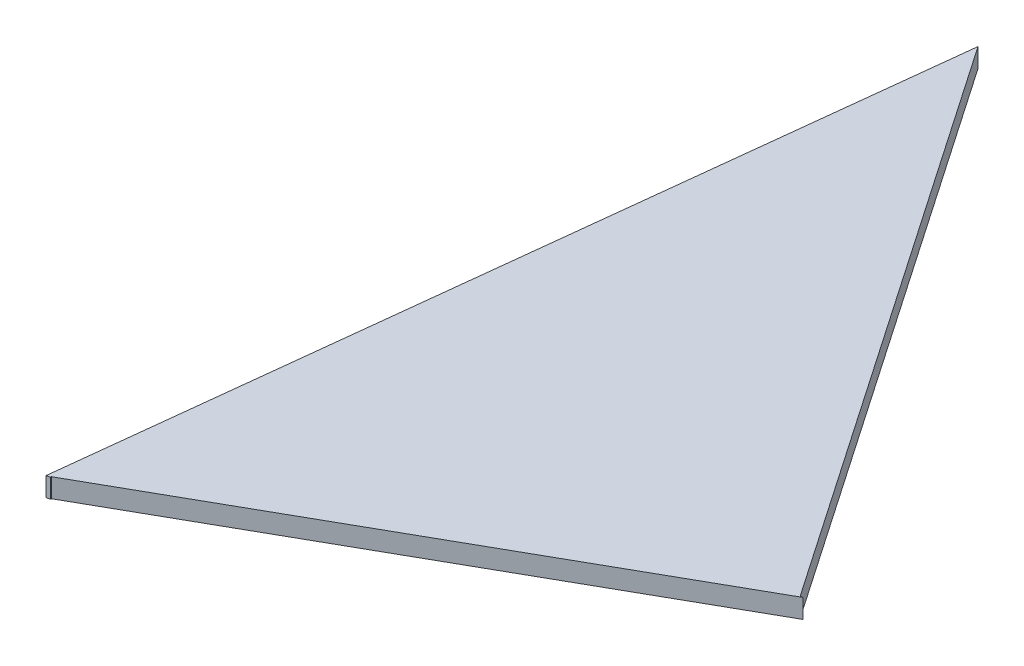
from build123d import *

# Parameters (mm, degrees)
BOSS_EXTRU_1_DEPTH = 2


with BuildPart() as part:
    # Esquisse1 → Boss.-Extru.1 (new body)
    with BuildSketch(Plane(origin=(0, 0, 0), x_dir=(1, 0, 0), z_dir=(0, 1, 0))):
        Polygon((50.690354459, 28.590988497), (50.434296073, 28.562722207), (9.89415959, 87.728993692), (0, 0), (0.377483634, 0.085389692), (0.377483634, 0.178570482), align=None)
    extrude(amount=BOSS_EXTRU_1_DEPTH)


solid = part.part
